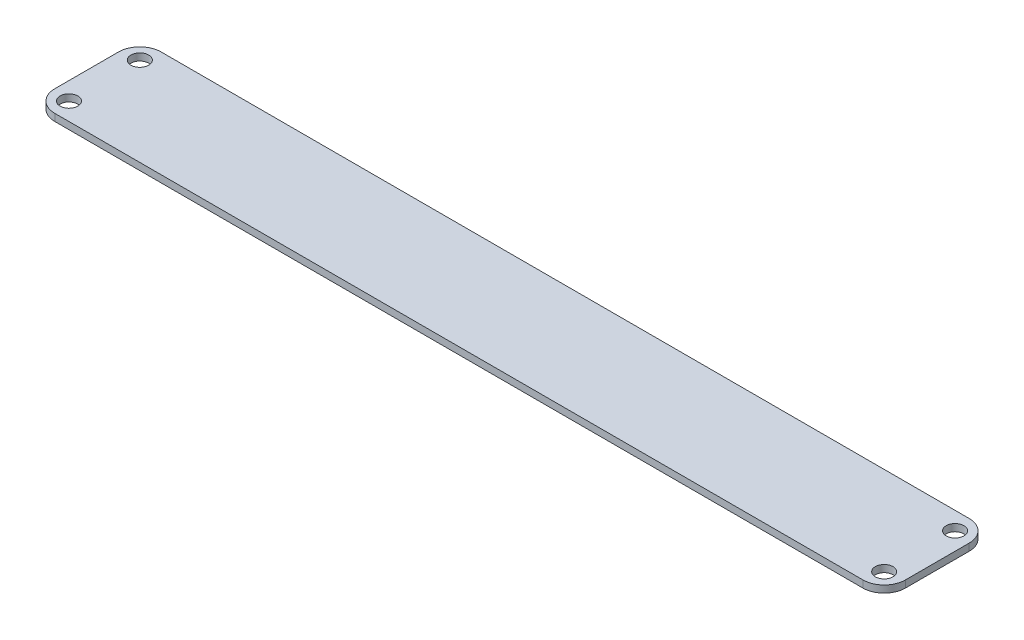
from build123d import *

# Parameters (mm, degrees)
SKETCH1_W               = 120
SKETCH1_H               = 15
BOSS_EXTRUDE1_DEPTH     = 1
FILLET1_R               = 3
SKETCH3_R               = 1.25
CUT_EXTRUDE1_DEPTH      = 1
MIRROR2_COPY_1_SKETCH_R = 1.25
MIRROR2_COPY_1_DEPTH    = 1


with BuildPart() as part:
    # Sketch1 → Boss-Extrude1 (new body)
    with BuildSketch(Plane(origin=(0, 0, 0), x_dir=(1, 0, 0), z_dir=(0, 1, 0))):
        Rectangle(SKETCH1_W, SKETCH1_H)
    extrude(amount=BOSS_EXTRUDE1_DEPTH)

    # Fillet1
    fillet1_edges = [part.edges().sort_by_distance(p)[0] for p in [
        (60, 0.5, 7.5),
        (-60, 0.5, 7.5),
        (-60, 0.5, -7.5),
        (60, 0.5, -7.5),
    ]]
    fillet(fillet1_edges, radius=FILLET1_R)

    # Sketch3 → Cut-Extrude1 (cut)
    with BuildSketch(Plane(origin=(0, 1, 0), x_dir=(1, 0, 0), z_dir=(0, 1, 0))):
        with Locations((-57.5, 5)):
            Circle(SKETCH3_R)
    cut_extrude1 = extrude(amount=-CUT_EXTRUDE1_DEPTH, mode=Mode.SUBTRACT)

    # Mirror1: Cut-Extrude1 across plane
    add(cut_extrude1.mirror(Plane.XY), mode=Mode.SUBTRACT)

    # Mirror2: Cut-Extrude1 across plane
    add(cut_extrude1.mirror(Plane(origin=(0, 0, 0), x_dir=(0, 0, 1), z_dir=(1, 0, 0))), mode=Mode.SUBTRACT)

    # Mirror2 copy 1 sketch → Mirror2 copy 1 (cut)
    with BuildSketch(Plane(origin=(0, 1, 0), x_dir=(-1, 0, 0), z_dir=(0, 1, 0))):
        with Locations((-57.5, 5)):
            Circle(MIRROR2_COPY_1_SKETCH_R)
    extrude(amount=-MIRROR2_COPY_1_DEPTH, mode=Mode.SUBTRACT)


solid = part.part
